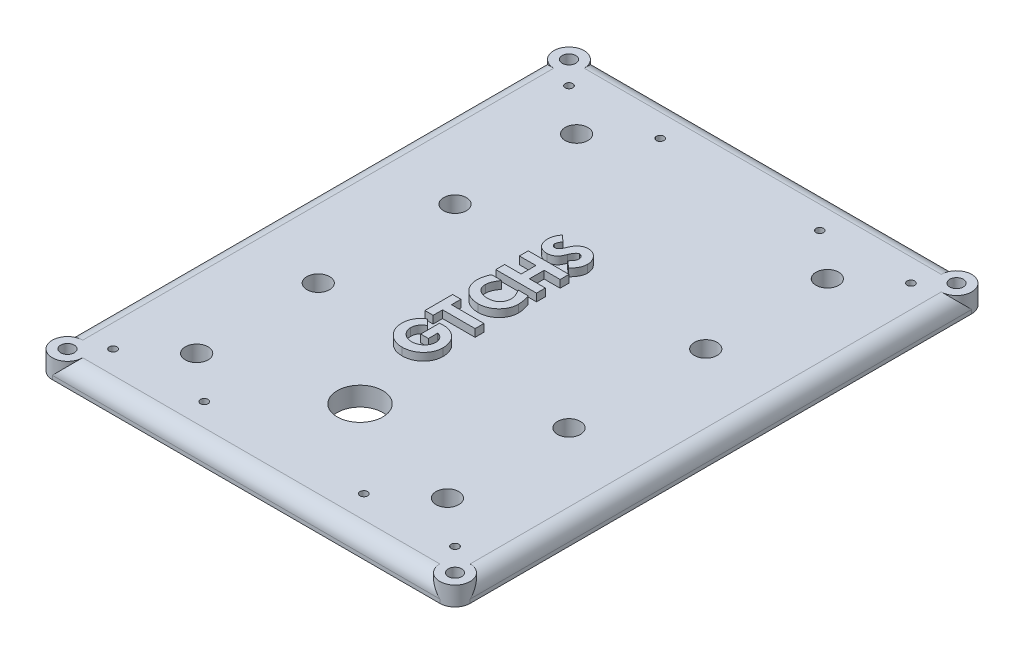
from build123d import *
from OCP.BRepAlgoAPI import BRepAlgoAPI_Cut
from OCP.TopTools import TopTools_ListOfShape

# Parameters (mm, degrees)
SKETCH1_W             = 69.85
SKETCH1_H             = 88.9
BOSS_EXTRUDE1_DEPTH   = 3.175
SKETCH2_R             = 1.905
SKETCH2_R_2           = 3.81
SKETCH2_R_3           = 0.635
CUT_EXTRUDE1_DEPTH    = 114.103108379
FILLET1_R             = 2.54
SKETCH3_R             = 2.54
CUT_EXTRUDE2_DEPTH    = 2.54
SKETCH3_2_R           = 2.54
BOSS_EXTRUDE2_DEPTH   = 2.54
F_4_40_TAPPED_HOLE1_D = 2.2606
BOSS_EXTRUDE3_DEPTH   = 1.27


with BuildPart() as part:
    # Sketch1 → Boss-Extrude1 (new body)
    with BuildSketch(Plane(origin=(0, 0, 0), x_dir=(1, 0, 0), z_dir=(0, 1, 0))):
        with Locations((34.925, -44.45)):
            Rectangle(SKETCH1_W, SKETCH1_H)
    extrude(amount=BOSS_EXTRUDE1_DEPTH)

    # Sketch2 → Cut-Extrude1 (cut, through all)
    with BuildSketch(Plane(origin=(0, 3.175, 0), x_dir=(1, 0, 0), z_dir=(0, 1, 0))):
        with Locations((13.97, -12.7)):
            Circle(SKETCH2_R)
        with Locations((13.97, -33.02)):
            Circle(SKETCH2_R)
        with Locations((13.97, -55.88)):
            Circle(SKETCH2_R)
        with Locations((13.97, -76.2)):
            Circle(SKETCH2_R)
        with Locations((34.925, -69.85)):
            Circle(SKETCH2_R_2)
        with Locations((55.88, -76.2)):
            Circle(SKETCH2_R)
        with Locations((55.88, -55.88)):
            Circle(SKETCH2_R)
        with Locations((55.88, -33.02)):
            Circle(SKETCH2_R)
        with Locations((55.88, -12.7)):
            Circle(SKETCH2_R)
        with Locations((6.35, -82.55)):
            Circle(SKETCH2_R_3)
        with Locations((21.59, -82.55)):
            Circle(SKETCH2_R_3)
        with Locations((6.35, -6.35)):
            Circle(SKETCH2_R_3)
        with Locations((21.59, -6.35)):
            Circle(SKETCH2_R_3)
        with Locations((48.26, -82.55)):
            Circle(SKETCH2_R_3)
        with Locations((63.5, -82.55)):
            Circle(SKETCH2_R_3)
        with Locations((48.26, -6.35)):
            Circle(SKETCH2_R_3)
        with Locations((63.5, -6.35)):
            Circle(SKETCH2_R_3)
    extrude(amount=-CUT_EXTRUDE1_DEPTH, mode=Mode.SUBTRACT)

    # Fillet1
    fillet1_edges = [part.edges().sort_by_distance(p)[0] for p in [
        (0, 1.5875, 88.9),
        (69.85, 1.5875, 88.9),
        (69.85, 1.5875, 0),
        (0, 1.5875, 0),
        (34.925, 3.175, 0),
        (69.85, 3.175, 44.45),
        (34.925, 3.175, 88.9),
        (0, 3.175, 44.45),
    ]]
    fillet(fillet1_edges, radius=FILLET1_R)


with BuildPart() as cut_extrude2_tool:
    # Sketch3 → Cut-Extrude2 (new body)
    with BuildSketch(Plane(origin=(0, 3.175, 0), x_dir=(1, 0, 0), z_dir=(0, 1, 0))):
        with Locations((2.54, -86.36)):
            Circle(SKETCH3_R)
        with Locations((2.54, -2.54)):
            Circle(SKETCH3_R)
        with Locations((67.31, -2.54)):
            Circle(SKETCH3_R)
        with Locations((67.31, -86.36)):
            Circle(SKETCH3_R)
    extrude(amount=-CUT_EXTRUDE2_DEPTH)


with BuildPart() as part_1:
    add(part.part)

    # Cut-Extrude2: cut by cut_extrude2_tool, with a tolerance
    cut_extrude2_stock = TopTools_ListOfShape()
    cut_extrude2_stock.Append(part_1.part.wrapped)
    cut_extrude2_tools = TopTools_ListOfShape()
    cut_extrude2_tools.Append(cut_extrude2_tool.part.wrapped)
    cut_extrude2_cut = BRepAlgoAPI_Cut()
    cut_extrude2_cut.SetArguments(cut_extrude2_stock)
    cut_extrude2_cut.SetTools(cut_extrude2_tools)
    cut_extrude2_cut.SetFuzzyValue(0.00001)
    cut_extrude2_cut.Build()
    add(Compound.cast(cut_extrude2_cut.Shape()).solids(), mode=Mode.REPLACE)

    # Sketch3_2 → Boss-Extrude2 (add)
    with BuildSketch(Plane(origin=(0, 3.175, 0), x_dir=(1, 0, 0), z_dir=(0, 1, 0))):
        with Locations((2.54, -86.36)):
            Circle(SKETCH3_2_R)
        with Locations((2.54, -2.54)):
            Circle(SKETCH3_2_R)
        with Locations((67.31, -2.54)):
            Circle(SKETCH3_2_R)
        with Locations((67.31, -86.36)):
            Circle(SKETCH3_2_R)
    extrude(amount=-BOSS_EXTRUDE2_DEPTH)

    # 4-40 Tapped Hole1 (through all)
    with Locations(Plane(origin=(0, 3.175, 0), x_dir=(1, 0, 0), z_dir=(0, 1, 0))):
        with Locations((2.54, -2.54), (67.31, -2.54), (67.31, -86.36), (2.54, -86.36)):
            Hole(F_4_40_TAPPED_HOLE1_D / 2)

    # Sketch6 → Boss-Extrude3 (add)
    with BuildSketch(Plane(origin=(0, 3.175, 0), x_dir=(1, 0, 0), z_dir=(0, 1, 0))):
        with BuildLine():
            Line((28.686848582, -29.789418627), (29.692603954, -30.705704963))
            add(Edge.make_bspline(
                [(29.692603954, -30.705704963), (29.661454086, -30.760557438), (29.601909062, -30.865411555), (29.52116376, -31.018473655), (29.453326683, -31.160028665), (29.397395833, -31.289577293), (29.353598792, -31.406854811), (29.322444407, -31.511896777), (29.301983172, -31.605264333), (29.299063402, -31.66407067), (29.29770614, -31.69140693)],
                knots=[0, 0, 0, 0, 1.413945109, 2.702849125, 3.878275411, 4.931628496, 5.86516359, 6.682128765, 7.387384537, 8, 8, 8, 8], degree=3))
            add(Edge.make_bspline(
                [(29.29770614, -31.69140693), (29.299454718, -31.728756569), (29.302938458, -31.803169253), (29.341157248, -31.908749956), (29.397491048, -32.007916651), (29.477803607, -32.093669101), (29.572604797, -32.166074697), (29.67867709, -32.21936877), (29.794123968, -32.251387143), (29.873909621, -32.255450731), (29.914733975, -32.257529969)],
                knots=[0, 0, 0, 0, 0.961640843, 1.915902787, 2.868960264, 3.894625119, 4.928868786, 5.93952035, 6.945703279, 8, 8, 8, 8], degree=3))
            add(Edge.make_bspline(
                [(29.914733975, -32.257529969), (29.956247678, -32.25495519), (30.040011583, -32.249759952), (30.161863001, -32.203154817), (30.277247946, -32.128097875), (30.388842292, -32.026229617), (30.495462828, -31.895661453), (30.59847161, -31.737299168), (30.69679519, -31.550033709), (30.754434687, -31.413196596), (30.784743223, -31.341243633)],
                knots=[0, 0, 0, 0, 0.74390433, 1.501006341, 2.311067879, 3.207397626, 4.204773914, 5.332457271, 6.597327889, 8, 8, 8, 8], degree=3))
            add(Edge.make_bspline(
                [(30.784743223, -31.341243633), (30.830757316, -31.235999926), (30.91693804, -31.038886858), (31.049261733, -30.767617945), (31.175038777, -30.54084936), (31.296045224, -30.349733624), (31.429510736, -30.189459055), (31.580102021, -30.046351833), (31.754293202, -29.918485187), (31.947671074, -29.805536565), (32.155346415, -29.709049544), (32.375886694, -29.641479102), (32.604956796, -29.600019571), (32.760599889, -29.59467645), (32.839445916, -29.591969719)],
                knots=[0, 0, 0, 0, 1.427753394, 2.674068192, 3.749944303, 4.650538315, 5.48118809, 6.335693293, 7.226710127, 8.160685154, 9.116024288, 10.066217931, 11.02038034, 12, 12, 12, 12], degree=3))
            add(Edge.make_bspline(
                [(32.839445916, -29.591969719), (32.911544758, -29.594046062), (33.054424106, -29.59816078), (33.265211685, -29.631006506), (33.468727209, -29.68733358), (33.66540979, -29.764543742), (33.854493234, -29.864148456), (34.036381074, -29.985103993), (34.209163157, -30.130292893), (34.374272299, -30.293418201), (34.524834416, -30.472026261), (34.659161908, -30.659621119), (34.772315463, -30.855761132), (34.863425769, -31.061440019), (34.936434985, -31.27383298), (34.987711068, -31.495011918), (35.016864137, -31.724044236), (35.021417875, -31.879519502), (35.023724454, -31.958271469)],
                knots=[0, 0, 0, 0, 0.969711709, 1.9216921, 2.861530032, 3.805736964, 4.758797567, 5.73156427, 6.738655078, 7.790376144, 8.850639914, 9.877588377, 10.890956021, 11.891180547, 12.899695947, 13.908211347, 14.940458665, 16, 16, 16, 16], degree=3))
            add(Edge.make_bspline(
                [(35.023724454, -31.958271469), (35.020175077, -32.045883817), (35.013045816, -32.22186152), (34.963529693, -32.48525335), (34.880522582, -32.74721187), (34.76551523, -33.008747784), (34.617696957, -33.268835381), (34.43683291, -33.526974977), (34.225137098, -33.785643281), (34.065035142, -33.949888696), (33.982489981, -34.034570136)],
                knots=[0, 0, 0, 0, 0.881518164, 1.770612752, 2.687112475, 3.641776849, 4.640470727, 5.692642331, 6.810375498, 8, 8, 8, 8], degree=3))
            Line((33.982489981, -34.034570136), (32.851786472, -33.065836434))
            add(Edge.make_bspline(
                [(32.851786472, -33.065836434), (32.906503474, -33.012027713), (33.011899999, -32.908380727), (33.152473536, -32.747460484), (33.272850821, -32.589992297), (33.369830092, -32.434245765), (33.447913922, -32.281616265), (33.501361332, -32.130623811), (33.53646104, -31.981980397), (33.540748073, -31.883383668), (33.542857648, -31.834865902)],
                knots=[0, 0, 0, 0, 1.270588243, 2.447421875, 3.535764099, 4.549482716, 5.482551327, 6.368740979, 7.197285305, 8, 8, 8, 8], degree=3))
            add(Edge.make_bspline(
                [(33.542857648, -31.834865902), (33.539978055, -31.790371305), (33.534138347, -31.700137925), (33.492185724, -31.56719888), (33.421845378, -31.438476774), (33.328463383, -31.318553053), (33.223146523, -31.211914269), (33.109427527, -31.133092419), (32.991633337, -31.081834309), (32.910363689, -31.075807684), (32.870297308, -31.072836525)],
                knots=[0, 0, 0, 0, 0.966001092, 1.959014146, 2.99862995, 4.138184106, 5.252039888, 6.240518037, 7.132565744, 8, 8, 8, 8], degree=3))
            add(Edge.make_bspline(
                [(32.870297308, -31.072836525), (32.829099945, -31.076099174), (32.743273643, -31.082896239), (32.619416761, -31.142926385), (32.497442707, -31.233371598), (32.377181796, -31.359258427), (32.259073775, -31.520434881), (32.141157178, -31.715373407), (32.023558607, -31.94546254), (31.951915759, -32.113069905), (31.913904162, -32.201997464)],
                knots=[0, 0, 0, 0, 0.634803569, 1.322483769, 2.091354202, 2.980595057, 4.004086041, 5.179309828, 6.503424416, 8, 8, 8, 8], degree=3))
            add(Edge.make_bspline(
                [(31.913904162, -32.201997464), (31.891884139, -32.253968133), (31.849476126, -32.354057621), (31.786501565, -32.498648075), (31.723665558, -32.630060936), (31.66270988, -32.749481009), (31.606316063, -32.858440736), (31.549735108, -32.954427125), (31.49522873, -33.038863858), (31.425634642, -33.136369687), (31.326824299, -33.244700564), (31.188929839, -33.361715252), (31.02756322, -33.467690126), (30.846587738, -33.561498315), (30.652992898, -33.63954698), (30.453607949, -33.696904965), (30.25126775, -33.732550857), (30.115410371, -33.736446478), (30.04739496, -33.738396775)],
                knots=[0, 0, 0, 0, 1.040648596, 2.00416861, 2.907364072, 3.725619162, 4.476221156, 5.168848869, 5.778895726, 6.328820283, 7.375925913, 8.472050806, 9.655235354, 10.927294023, 12.224710675, 13.496945958, 14.746875221, 16, 16, 16, 16], degree=3))
            add(Edge.make_bspline(
                [(30.04739496, -33.738396775), (29.973804584, -33.736478721), (29.829233275, -33.732710627), (29.617607411, -33.70728988), (29.417063197, -33.659823447), (29.227202813, -33.597214099), (29.047206268, -33.516482138), (28.87934615, -33.415429543), (28.720552987, -33.297814621), (28.57514228, -33.16196472), (28.442025621, -33.013213175), (28.327467891, -32.850458855), (28.231923741, -32.675963773), (28.150766426, -32.492211428), (28.08905682, -32.29664169), (28.046389282, -32.089861759), (28.019647561, -31.872071532), (28.016099548, -31.722851271), (28.014288242, -31.646672412)],
                knots=[0, 0, 0, 0, 1.076481044, 2.114791108, 3.110920092, 4.086071964, 5.035326451, 5.989840335, 6.946544492, 7.920506429, 8.895513265, 9.861660988, 10.824494904, 11.801240755, 12.795522396, 13.817772392, 14.88594479, 16, 16, 16, 16], degree=3))
            add(Edge.make_bspline(
                [(28.014288242, -31.646672412), (28.016413099, -31.556088743), (28.020578937, -31.378497076), (28.051833634, -31.117749779), (28.104327959, -30.867853424), (28.177996012, -30.629181665), (28.273082458, -30.4013707), (28.389235739, -30.184943844), (28.526029622, -29.978702051), (28.633097468, -29.852683524), (28.686848582, -29.789418627)],
                knots=[0, 0, 0, 0, 1.075199775, 2.10795745, 3.112419521, 4.102910335, 5.068793094, 6.038295424, 7.015168318, 8, 8, 8, 8], degree=3))
        make_face()
        Polygon((28.113012695, -40.352935172), (28.113012695, -38.872068366), (30.877297399, -38.872068366), (30.877297399, -36.403957024), (28.113012695, -36.403957024), (28.113012695, -34.923090219), (34.925, -34.923090219), (34.925, -36.403957024), (32.25943975, -36.403957024), (32.25943975, -38.872068366), (34.925, -38.872068366), (34.925, -40.352935172), align=None)
        with BuildLine():
            Line((28.50791051, -41.438904162), (30.186226223, -41.438904162))
            add(Edge.make_bspline(
                [(30.186226223, -41.438904162), (30.123594919, -41.528782983), (30.002368541, -41.702748445), (29.841329112, -41.965721269), (29.705157656, -42.22010154), (29.592860235, -42.466047671), (29.505794718, -42.703763293), (29.443582034, -42.932795444), (29.404008466, -43.153382655), (29.398915624, -43.298062714), (29.396430593, -43.368658718)],
                knots=[0, 0, 0, 0, 1.241833359, 2.40363763, 3.493801599, 4.511340002, 5.466637272, 6.360397669, 7.199963188, 8, 8, 8, 8], degree=3))
            add(Edge.make_bspline(
                [(29.396430593, -43.368658718), (29.39811699, -43.436116523), (29.401414713, -43.568029189), (29.42994269, -43.760898961), (29.476026946, -43.942783263), (29.539197788, -44.115312953), (29.624050701, -44.27567344), (29.723364963, -44.428713024), (29.846240793, -44.567126702), (29.982530424, -44.697721014), (30.137617578, -44.812068138), (30.304002177, -44.914978863), (30.484457474, -44.999686356), (30.677270129, -45.068977), (30.8823516, -45.125044269), (31.100881365, -45.16255073), (31.331311848, -45.186319653), (31.489121996, -45.189040497), (31.569911144, -45.190433403)],
                knots=[0, 0, 0, 0, 1.012878061, 1.98066698, 2.921068932, 3.827784736, 4.732887135, 5.641180637, 6.561058527, 7.506301013, 8.471775567, 9.449377552, 10.440945771, 11.459813771, 12.524045296, 13.630086472, 14.786749164, 16, 16, 16, 16], degree=3))
            add(Edge.make_bspline(
                [(31.569911144, -45.190433403), (31.646594947, -45.189145826), (31.796269927, -45.186632674), (32.015087622, -45.161380898), (32.221993338, -45.119972822), (32.417164509, -45.062843421), (32.601345282, -44.990585008), (32.772410145, -44.898911471), (32.932332216, -44.792228997), (33.078851296, -44.669933224), (33.212087057, -44.535108715), (33.325847865, -44.385883287), (33.424603856, -44.227269495), (33.504852099, -44.057019017), (33.566882054, -43.875397965), (33.609344076, -43.682867153), (33.636271869, -43.479968152), (33.639785878, -43.340979706), (33.641582102, -43.269934264)],
                knots=[0, 0, 0, 0, 1.154531469, 2.253467733, 3.312042825, 4.329009495, 5.31264158, 6.286130805, 7.246221043, 8.203057576, 9.155937238, 10.094612948, 11.023042237, 11.965289009, 12.922846064, 13.907300903, 14.930294312, 16, 16, 16, 16], degree=3))
            add(Edge.make_bspline(
                [(33.641582102, -43.269934264), (33.639378913, -43.20451056), (33.634843403, -43.069828589), (33.600358153, -42.863810086), (33.545656059, -42.648378739), (33.469899478, -42.423517413), (33.371205943, -42.189627582), (33.252612784, -41.946376411), (33.111218962, -41.694007805), (33.005280006, -41.525843136), (32.950510926, -41.438904162)],
                knots=[0, 0, 0, 0, 0.791827157, 1.630064259, 2.522406844, 3.481140236, 4.499713243, 5.593916541, 6.75608576, 8, 8, 8, 8], degree=3))
            Line((32.950510926, -41.438904162), (34.628826639, -41.438904162))
            add(Edge.make_bspline(
                [(34.628826639, -41.438904162), (34.660212053, -41.537465371), (34.721280326, -41.729241171), (34.801641101, -42.012139779), (34.869845462, -42.282150939), (34.925636496, -42.539875288), (34.969217987, -42.785290506), (35.000174874, -43.01841572), (35.019804165, -43.238744626), (35.022447669, -43.381476773), (35.023724454, -43.450414906)],
                knots=[0, 0, 0, 0, 1.206326171, 2.347213182, 3.429342619, 4.453838443, 5.422025358, 6.335473078, 7.196050908, 8, 8, 8, 8], degree=3))
            add(Edge.make_bspline(
                [(35.023724454, -43.450414906), (35.020995787, -43.563717935), (35.015612455, -43.787251177), (34.965882113, -44.115333794), (34.887853599, -44.431003745), (34.775594776, -44.733161949), (34.63328717, -45.022796567), (34.459458994, -45.299193037), (34.252361843, -45.561079061), (34.016497855, -45.806448389), (33.759873231, -46.0322622), (33.48494708, -46.229563152), (33.196169978, -46.396620407), (32.893161829, -46.533034012), (32.577174946, -46.640266211), (32.246410759, -46.715677342), (31.901799968, -46.761026264), (31.667230087, -46.766997534), (31.54831517, -46.770024662)],
                knots=[0, 0, 0, 0, 1.01569195, 2.003837995, 2.969172361, 3.927862474, 4.889034351, 5.858963009, 6.850815319, 7.878343884, 8.907899133, 9.912621006, 10.908571654, 11.895252853, 12.888466017, 13.896485118, 14.933625675, 16, 16, 16, 16], degree=3))
            add(Edge.make_bspline(
                [(31.54831517, -46.770024662), (31.427328406, -46.767142583), (31.188563978, -46.761454872), (30.837886661, -46.71396868), (30.501343412, -46.637545584), (30.180056583, -46.527908192), (29.871068485, -46.391155592), (29.577861233, -46.220093886), (29.297743369, -46.019989094), (29.037107341, -45.78979284), (28.797458153, -45.539347986), (28.588211966, -45.271584709), (28.411117554, -44.990369081), (28.26445888, -44.696450149), (28.153809012, -44.387378958), (28.073604344, -44.066048497), (28.022035913, -43.731798292), (28.016893517, -43.504080175), (28.014288242, -43.388712123)],
                knots=[0, 0, 0, 0, 1.065769973, 2.10327105, 3.112280989, 4.102394323, 5.090151341, 6.084929607, 7.088348855, 8.119020143, 9.144609309, 10.138912774, 11.108153246, 12.068659008, 13.027549601, 13.994627061, 14.984024751, 16, 16, 16, 16], degree=3))
            add(Edge.make_bspline(
                [(28.014288242, -43.388712123), (28.015795268, -43.31204108), (28.018836204, -43.157331347), (28.043190006, -42.923438271), (28.081809133, -42.685494576), (28.135934987, -42.443421607), (28.2058625, -42.197390779), (28.29119186, -41.947342124), (28.39086252, -41.692717401), (28.468483389, -41.524400081), (28.50791051, -41.438904162)],
                knots=[0, 0, 0, 0, 0.907364679, 1.830914789, 2.780470439, 3.759471137, 4.765198479, 5.80644882, 6.88579694, 8, 8, 8, 8], degree=3))
        make_face()
        Polygon((28.113012695, -52.199869615), (28.113012695, -47.559820291), (29.495155047, -47.559820291), (29.495155047, -49.13941155), (34.925, -49.13941155), (34.925, -50.620278356), (29.495155047, -50.620278356), (29.495155047, -52.199869615), align=None)
        with BuildLine():
            Line((29.566113248, -53.187114152), (30.482399584, -54.165103271))
            add(Edge.make_bspline(
                [(30.482399584, -54.165103271), (30.395637532, -54.217014538), (30.227540951, -54.317589689), (30.004811094, -54.498958442), (29.81541632, -54.697331421), (29.663238975, -54.914154119), (29.543027421, -55.141080864), (29.460143743, -55.376272154), (29.406049399, -55.615752151), (29.399636107, -55.777832908), (29.396430593, -55.85884468)],
                knots=[0, 0, 0, 0, 1.147523759, 2.223262528, 3.252299175, 4.254041439, 5.223526551, 6.16040899, 7.080529183, 8, 8, 8, 8], degree=3))
            add(Edge.make_bspline(
                [(29.396430593, -55.85884468), (29.39802412, -55.924262166), (29.401165163, -56.053208315), (29.431785861, -56.243551943), (29.481038672, -56.427012398), (29.549333424, -56.60462472), (29.63774055, -56.77453632), (29.745728932, -56.937962787), (29.872070709, -57.095659541), (30.018036804, -57.24294262), (30.174904455, -57.379972758), (30.342587973, -57.49840224), (30.515293464, -57.602101653), (30.697652462, -57.683210129), (30.885600899, -57.749269213), (31.081446563, -57.792737402), (31.283126672, -57.822220209), (31.420172934, -57.825499743), (31.489697525, -57.827163475)],
                knots=[0, 0, 0, 0, 0.985537611, 1.942619422, 2.897815975, 3.845021753, 4.805362578, 5.779278347, 6.793747101, 7.846181755, 8.901353269, 9.929500475, 10.93719454, 11.932831472, 12.932984334, 13.93520769, 14.952515449, 16, 16, 16, 16], degree=3))
            add(Edge.make_bspline(
                [(31.489697525, -57.827163475), (31.563302313, -57.825297486), (31.708412313, -57.821618734), (31.921720061, -57.795153889), (32.126417394, -57.750775467), (32.321742369, -57.686499989), (32.509426054, -57.606912543), (32.687324004, -57.506715589), (32.858093694, -57.391248455), (33.016744707, -57.257371968), (33.163069048, -57.112001668), (33.290862044, -56.957021414), (33.398755384, -56.793851114), (33.48895563, -56.625096618), (33.557152789, -56.446575946), (33.606216716, -56.262046175), (33.636930693, -56.069658887), (33.640012671, -55.939174279), (33.641582102, -55.872727806)],
                knots=[0, 0, 0, 0, 1.092518895, 2.153873719, 3.185496232, 4.196926922, 5.202232576, 6.206842476, 7.22310075, 8.258106565, 9.283639414, 10.281527883, 11.234220682, 12.183451639, 13.116211746, 14.064214243, 15.014242847, 16, 16, 16, 16], degree=3))
            add(Edge.make_bspline(
                [(33.641582102, -55.872727806), (33.638562667, -55.800001771), (33.632505716, -55.654114235), (33.584599096, -55.437609623), (33.504119008, -55.226694312), (33.414781353, -55.055331105), (33.32255302, -54.924814822), (33.241742187, -54.827824511), (33.142042627, -54.74116097), (33.033264945, -54.654995946), (32.907958378, -54.577356729), (32.771644075, -54.500740398), (32.618830339, -54.433883547), (32.512073174, -54.392961084), (32.456888658, -54.371807596)],
                knots=[0, 0, 0, 0, 1.272521813, 2.552663205, 3.860239315, 5.217478356, 5.921794779, 6.656081015, 7.420911279, 8.22942191, 9.083508703, 9.998124195, 10.9651978, 12, 12, 12, 12], degree=3))
            Line((32.456888658, -54.371807596), (32.456888658, -55.951398855))
            Line((32.456888658, -55.951398855), (31.17347076, -55.951398855))
            Line((31.17347076, -55.951398855), (31.17347076, -52.792216337))
            Line((31.17347076, -52.792216337), (32.057363134, -52.792216337))
            add(Edge.make_bspline(
                [(32.057363134, -52.792216337), (32.114492311, -52.793906429), (32.230675601, -52.79734356), (32.40624045, -52.819179092), (32.584770431, -52.85744418), (32.766668288, -52.907467611), (32.950877687, -52.975579305), (33.139133914, -53.054690053), (33.32905368, -53.15225088), (33.521311038, -53.259185822), (33.707966466, -53.380122434), (33.884285463, -53.511418649), (34.048175605, -53.651614801), (34.198407895, -53.801572759), (34.334461826, -53.961413241), (34.458483545, -54.129492413), (34.568105465, -54.307897344), (34.696259228, -54.554827305), (34.824416676, -54.87328638), (34.941340462, -55.259920031), (35.009364684, -55.650772184), (35.018945484, -55.912072194), (35.023724454, -56.042410461)],
                knots=[0, 0, 0, 0, 0.705011764, 1.433778513, 2.179176997, 2.956617155, 3.759456954, 4.600932416, 5.474911885, 6.392574261, 7.314787996, 8.217053892, 9.103474325, 9.973876484, 10.83345739, 11.691350544, 12.548891664, 13.414470072, 15.121800209, 16.776087869, 18.391890153, 20, 20, 20, 20], degree=3))
            add(Edge.make_bspline(
                [(35.023724454, -56.042410461), (35.02098332, -56.158275918), (35.015586357, -56.386401099), (34.966234056, -56.721350309), (34.886514025, -57.042624697), (34.772358201, -57.349715386), (34.62936557, -57.644298644), (34.451030623, -57.923617034), (34.242551553, -58.189910401), (34.0023546, -58.437406353), (33.741315233, -58.66445002), (33.46168247, -58.863079036), (33.16804337, -59.032822589), (32.85706743, -59.1685), (32.531643503, -59.275231278), (32.191006713, -59.352885431), (31.834892015, -59.397683878), (31.592659881, -59.403699663), (31.469644121, -59.406754734)],
                knots=[0, 0, 0, 0, 1.018439304, 2.005184769, 2.970307658, 3.924564099, 4.881131972, 5.844590261, 6.833323088, 7.850305721, 8.872952642, 9.87171652, 10.862226308, 11.850286777, 12.849838563, 13.87003315, 14.918312415, 16, 16, 16, 16], degree=3))
            add(Edge.make_bspline(
                [(31.469644121, -59.406754734), (31.352749595, -59.404022804), (31.122066294, -59.398631527), (30.782714271, -59.348843183), (30.456112753, -59.270659476), (30.142327992, -59.161098024), (29.842966543, -59.017031775), (29.554720798, -58.844454368), (29.281165417, -58.637634958), (29.023906226, -58.402847213), (28.788356583, -58.14674747), (28.581930769, -57.873846018), (28.406612723, -57.58877597), (28.261701745, -57.29107913), (28.15026439, -56.979598574), (28.072275716, -56.65529809), (28.022312462, -56.318541591), (28.01699093, -56.089380624), (28.014288242, -55.972994829)],
                knots=[0, 0, 0, 0, 1.035472162, 2.043433032, 3.03267704, 4.008424793, 4.982766813, 5.972199743, 6.981149093, 8.016661366, 9.055247556, 10.0605574, 11.044570756, 12.016779007, 12.989755954, 13.970143149, 14.969080535, 16, 16, 16, 16], degree=3))
            add(Edge.make_bspline(
                [(28.014288242, -55.972994829), (28.015370741, -55.898388851), (28.017501845, -55.751512879), (28.037479577, -55.534335674), (28.065078975, -55.323248717), (28.109297176, -55.119550984), (28.163369535, -54.922153102), (28.228800931, -54.730814344), (28.31015066, -54.547096342), (28.401355641, -54.369457068), (28.502367665, -54.19698491), (28.620036242, -54.033996689), (28.745375435, -53.873858187), (28.886441265, -53.723498471), (29.038841184, -53.579303588), (29.201840972, -53.440320152), (29.378347882, -53.308813562), (29.502914772, -53.228076005), (29.566113248, -53.187114152)],
                knots=[0, 0, 0, 0, 1.070473, 2.107428455, 3.12813292, 4.123936429, 5.096106677, 6.064656899, 7.023032398, 7.976879507, 8.929898364, 9.888160204, 10.859742065, 11.846673545, 12.843706829, 13.869892268, 14.919298996, 16, 16, 16, 16], degree=3))
        make_face()
    extrude(amount=BOSS_EXTRUDE3_DEPTH)


solid = part_1.part
